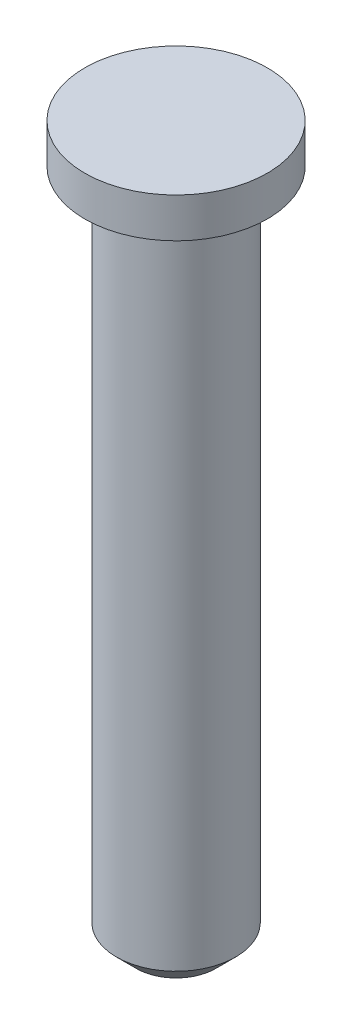
from build123d import *

# Parameters (mm, degrees)
CHAFL_N1_SIZE = 0.5


with BuildPart() as part:
    # Croquis1 → Revolución1 (revolve)
    with BuildSketch(Plane.XY):
        Polygon((0, 0), (2.3, 0), (2.3, -1), (1.5, -1), (1.5, -18), (0, -18), align=None)
    revolve(axis=Axis((0, 0, 0), (0, -1, 0)))

    # Chaflán1
    chafl_n1_edges = [part.edges().sort_by_distance(p)[0] for p in [
        (-1.5, -18, 0),
    ]]
    chamfer(chafl_n1_edges, length=CHAFL_N1_SIZE)


solid = part.part
